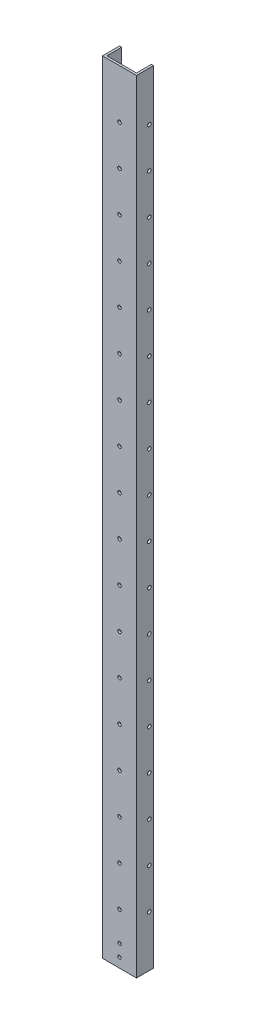
from build123d import *

# Parameters (mm, degrees)
BOSS_EXTRUDE1_DEPTH = 1168.4
CUT_EXTRUDE1_REACH  = 27.4
SKETCH2_R           = 2.667
CUT_EXTRUDE2_REACH  = 27.4
SKETCH3_R           = 2.5527
CUT_EXTRUDE3_REACH  = 52.8
SKETCH4_R           = 2.667


with BuildPart() as part:
    # Sketch1 → Boss-Extrude1 (new body)
    with BuildSketch(Plane(origin=(0, 0, 0), x_dir=(1, 0, 0), z_dir=(0, 1, 0))):
        Polygon((3.175, 3.175), (3.175, 25.4), (0, 25.4), (0, 0), (50.8, 0), (50.8, 25.4), (47.625, 25.4), (47.625, 3.175), align=None)
    extrude(amount=BOSS_EXTRUDE1_DEPTH)

    # Sketch2 → Cut-Extrude1 (cut, up to next)
    with BuildSketch(Plane.XY, mode=Mode.PRIVATE) as cut_extrude1_sk1:
        with Locations((25.4, 76.2)):
            Circle(SKETCH2_R)
    cut_extrude1_tool1 = extrude(cut_extrude1_sk1.sketch, amount=-CUT_EXTRUDE1_REACH, mode=Mode.PRIVATE) & part.part
    add(cut_extrude1_tool1.solids().sort_by_distance((25.4, 76.2, 0))[0], mode=Mode.SUBTRACT)
    # Sketch2 → Cut-Extrude1 (cut, up to next)
    with BuildSketch(Plane.XY, mode=Mode.PRIVATE) as cut_extrude1_sk2:
        with Locations((25.4, 136.144)):
            Circle(SKETCH2_R)
    cut_extrude1_tool2 = extrude(cut_extrude1_sk2.sketch, amount=-CUT_EXTRUDE1_REACH, mode=Mode.PRIVATE) & part.part
    add(cut_extrude1_tool2.solids().sort_by_distance((25.4, 136.144, 0))[0], mode=Mode.SUBTRACT)
    # Sketch2 → Cut-Extrude1 (cut, up to next)
    with BuildSketch(Plane.XY, mode=Mode.PRIVATE) as cut_extrude1_sk3:
        with Locations((25.4, 196.088)):
            Circle(SKETCH2_R)
    cut_extrude1_tool3 = extrude(cut_extrude1_sk3.sketch, amount=-CUT_EXTRUDE1_REACH, mode=Mode.PRIVATE) & part.part
    add(cut_extrude1_tool3.solids().sort_by_distance((25.4, 196.088, 0))[0], mode=Mode.SUBTRACT)
    # Sketch2 → Cut-Extrude1 (cut, up to next)
    with BuildSketch(Plane.XY, mode=Mode.PRIVATE) as cut_extrude1_sk4:
        with Locations((25.4, 256.032)):
            Circle(SKETCH2_R)
    cut_extrude1_tool4 = extrude(cut_extrude1_sk4.sketch, amount=-CUT_EXTRUDE1_REACH, mode=Mode.PRIVATE) & part.part
    add(cut_extrude1_tool4.solids().sort_by_distance((25.4, 256.032, 0))[0], mode=Mode.SUBTRACT)
    # Sketch2 → Cut-Extrude1 (cut, up to next)
    with BuildSketch(Plane.XY, mode=Mode.PRIVATE) as cut_extrude1_sk5:
        with Locations((25.4, 315.976)):
            Circle(SKETCH2_R)
    cut_extrude1_tool5 = extrude(cut_extrude1_sk5.sketch, amount=-CUT_EXTRUDE1_REACH, mode=Mode.PRIVATE) & part.part
    add(cut_extrude1_tool5.solids().sort_by_distance((25.4, 315.976, 0))[0], mode=Mode.SUBTRACT)
    # Sketch2 → Cut-Extrude1 (cut, up to next)
    with BuildSketch(Plane.XY, mode=Mode.PRIVATE) as cut_extrude1_sk6:
        with Locations((25.4, 375.92)):
            Circle(SKETCH2_R)
    cut_extrude1_tool6 = extrude(cut_extrude1_sk6.sketch, amount=-CUT_EXTRUDE1_REACH, mode=Mode.PRIVATE) & part.part
    add(cut_extrude1_tool6.solids().sort_by_distance((25.4, 375.92, 0))[0], mode=Mode.SUBTRACT)
    # Sketch2 → Cut-Extrude1 (cut, up to next)
    with BuildSketch(Plane.XY, mode=Mode.PRIVATE) as cut_extrude1_sk7:
        with Locations((25.4, 435.864)):
            Circle(SKETCH2_R)
    cut_extrude1_tool7 = extrude(cut_extrude1_sk7.sketch, amount=-CUT_EXTRUDE1_REACH, mode=Mode.PRIVATE) & part.part
    add(cut_extrude1_tool7.solids().sort_by_distance((25.4, 435.864, 0))[0], mode=Mode.SUBTRACT)
    # Sketch2 → Cut-Extrude1 (cut, up to next)
    with BuildSketch(Plane.XY, mode=Mode.PRIVATE) as cut_extrude1_sk8:
        with Locations((25.4, 495.808)):
            Circle(SKETCH2_R)
    cut_extrude1_tool8 = extrude(cut_extrude1_sk8.sketch, amount=-CUT_EXTRUDE1_REACH, mode=Mode.PRIVATE) & part.part
    add(cut_extrude1_tool8.solids().sort_by_distance((25.4, 495.808, 0))[0], mode=Mode.SUBTRACT)
    # Sketch2 → Cut-Extrude1 (cut, up to next)
    with BuildSketch(Plane.XY, mode=Mode.PRIVATE) as cut_extrude1_sk9:
        with Locations((25.4, 555.752)):
            Circle(SKETCH2_R)
    cut_extrude1_tool9 = extrude(cut_extrude1_sk9.sketch, amount=-CUT_EXTRUDE1_REACH, mode=Mode.PRIVATE) & part.part
    add(cut_extrude1_tool9.solids().sort_by_distance((25.4, 555.752, 0))[0], mode=Mode.SUBTRACT)
    # Sketch2 → Cut-Extrude1 (cut, up to next)
    with BuildSketch(Plane.XY, mode=Mode.PRIVATE) as cut_extrude1_sk10:
        with Locations((25.4, 615.696)):
            Circle(SKETCH2_R)
    cut_extrude1_tool10 = extrude(cut_extrude1_sk10.sketch, amount=-CUT_EXTRUDE1_REACH, mode=Mode.PRIVATE) & part.part
    add(cut_extrude1_tool10.solids().sort_by_distance((25.4, 615.696, 0))[0], mode=Mode.SUBTRACT)
    # Sketch2 → Cut-Extrude1 (cut, up to next)
    with BuildSketch(Plane.XY, mode=Mode.PRIVATE) as cut_extrude1_sk11:
        with Locations((25.4, 675.64)):
            Circle(SKETCH2_R)
    cut_extrude1_tool11 = extrude(cut_extrude1_sk11.sketch, amount=-CUT_EXTRUDE1_REACH, mode=Mode.PRIVATE) & part.part
    add(cut_extrude1_tool11.solids().sort_by_distance((25.4, 675.64, 0))[0], mode=Mode.SUBTRACT)
    # Sketch2 → Cut-Extrude1 (cut, up to next)
    with BuildSketch(Plane.XY, mode=Mode.PRIVATE) as cut_extrude1_sk12:
        with Locations((25.4, 735.584)):
            Circle(SKETCH2_R)
    cut_extrude1_tool12 = extrude(cut_extrude1_sk12.sketch, amount=-CUT_EXTRUDE1_REACH, mode=Mode.PRIVATE) & part.part
    add(cut_extrude1_tool12.solids().sort_by_distance((25.4, 735.584, 0))[0], mode=Mode.SUBTRACT)
    # Sketch2 → Cut-Extrude1 (cut, up to next)
    with BuildSketch(Plane.XY, mode=Mode.PRIVATE) as cut_extrude1_sk13:
        with Locations((25.4, 795.528)):
            Circle(SKETCH2_R)
    cut_extrude1_tool13 = extrude(cut_extrude1_sk13.sketch, amount=-CUT_EXTRUDE1_REACH, mode=Mode.PRIVATE) & part.part
    add(cut_extrude1_tool13.solids().sort_by_distance((25.4, 795.528, 0))[0], mode=Mode.SUBTRACT)
    # Sketch2 → Cut-Extrude1 (cut, up to next)
    with BuildSketch(Plane.XY, mode=Mode.PRIVATE) as cut_extrude1_sk14:
        with Locations((25.4, 855.472)):
            Circle(SKETCH2_R)
    cut_extrude1_tool14 = extrude(cut_extrude1_sk14.sketch, amount=-CUT_EXTRUDE1_REACH, mode=Mode.PRIVATE) & part.part
    add(cut_extrude1_tool14.solids().sort_by_distance((25.4, 855.472, 0))[0], mode=Mode.SUBTRACT)
    # Sketch2 → Cut-Extrude1 (cut, up to next)
    with BuildSketch(Plane.XY, mode=Mode.PRIVATE) as cut_extrude1_sk15:
        with Locations((25.4, 915.416)):
            Circle(SKETCH2_R)
    cut_extrude1_tool15 = extrude(cut_extrude1_sk15.sketch, amount=-CUT_EXTRUDE1_REACH, mode=Mode.PRIVATE) & part.part
    add(cut_extrude1_tool15.solids().sort_by_distance((25.4, 915.416, 0))[0], mode=Mode.SUBTRACT)
    # Sketch2 → Cut-Extrude1 (cut, up to next)
    with BuildSketch(Plane.XY, mode=Mode.PRIVATE) as cut_extrude1_sk16:
        with Locations((25.4, 975.36)):
            Circle(SKETCH2_R)
    cut_extrude1_tool16 = extrude(cut_extrude1_sk16.sketch, amount=-CUT_EXTRUDE1_REACH, mode=Mode.PRIVATE) & part.part
    add(cut_extrude1_tool16.solids().sort_by_distance((25.4, 975.36, 0))[0], mode=Mode.SUBTRACT)
    # Sketch2 → Cut-Extrude1 (cut, up to next)
    with BuildSketch(Plane.XY, mode=Mode.PRIVATE) as cut_extrude1_sk17:
        with Locations((25.4, 1035.304)):
            Circle(SKETCH2_R)
    cut_extrude1_tool17 = extrude(cut_extrude1_sk17.sketch, amount=-CUT_EXTRUDE1_REACH, mode=Mode.PRIVATE) & part.part
    add(cut_extrude1_tool17.solids().sort_by_distance((25.4, 1035.304, 0))[0], mode=Mode.SUBTRACT)
    # Sketch2 → Cut-Extrude1 (cut, up to next)
    with BuildSketch(Plane.XY, mode=Mode.PRIVATE) as cut_extrude1_sk18:
        with Locations((25.4, 1095.248)):
            Circle(SKETCH2_R)
    cut_extrude1_tool18 = extrude(cut_extrude1_sk18.sketch, amount=-CUT_EXTRUDE1_REACH, mode=Mode.PRIVATE) & part.part
    add(cut_extrude1_tool18.solids().sort_by_distance((25.4, 1095.248, 0))[0], mode=Mode.SUBTRACT)

    # Sketch3 → Cut-Extrude2 (cut, up to next)
    with BuildSketch(Plane.XY, mode=Mode.PRIVATE) as cut_extrude2_sk1:
        with Locations((25.4, 32.131)):
            Circle(SKETCH3_R)
    cut_extrude2_tool1 = extrude(cut_extrude2_sk1.sketch, amount=-CUT_EXTRUDE2_REACH, mode=Mode.PRIVATE) & part.part
    add(cut_extrude2_tool1.solids().sort_by_distance((25.4, 32.131, 0))[0], mode=Mode.SUBTRACT)
    # Sketch3 → Cut-Extrude2 (cut, up to next)
    with BuildSketch(Plane.XY, mode=Mode.PRIVATE) as cut_extrude2_sk2:
        with Locations((25.4, 14.2875)):
            Circle(SKETCH3_R)
    cut_extrude2_tool2 = extrude(cut_extrude2_sk2.sketch, amount=-CUT_EXTRUDE2_REACH, mode=Mode.PRIVATE) & part.part
    add(cut_extrude2_tool2.solids().sort_by_distance((25.4, 14.2875, 0))[0], mode=Mode.SUBTRACT)

    # Sketch4 → Cut-Extrude3 (cut, up to next)
    with BuildSketch(Plane.ZY.offset(-50.8), mode=Mode.PRIVATE) as cut_extrude3_sk1:
        with Locations((-19.05, 76.2)):
            Circle(SKETCH4_R)
    cut_extrude3_tool1 = extrude(cut_extrude3_sk1.sketch, amount=CUT_EXTRUDE3_REACH, mode=Mode.PRIVATE) & part.part
    add(cut_extrude3_tool1.solids().sort_by_distance((50.8, 76.2, -19.05))[0], mode=Mode.SUBTRACT)
    # Sketch4 → Cut-Extrude3 (cut, up to next)
    with BuildSketch(Plane.ZY.offset(-50.8), mode=Mode.PRIVATE) as cut_extrude3_sk2:
        with Locations((-19.05, 136.144)):
            Circle(SKETCH4_R)
    cut_extrude3_tool2 = extrude(cut_extrude3_sk2.sketch, amount=CUT_EXTRUDE3_REACH, mode=Mode.PRIVATE) & part.part
    add(cut_extrude3_tool2.solids().sort_by_distance((50.8, 136.144, -19.05))[0], mode=Mode.SUBTRACT)
    # Sketch4 → Cut-Extrude3 (cut, up to next)
    with BuildSketch(Plane.ZY.offset(-50.8), mode=Mode.PRIVATE) as cut_extrude3_sk3:
        with Locations((-19.05, 196.088)):
            Circle(SKETCH4_R)
    cut_extrude3_tool3 = extrude(cut_extrude3_sk3.sketch, amount=CUT_EXTRUDE3_REACH, mode=Mode.PRIVATE) & part.part
    add(cut_extrude3_tool3.solids().sort_by_distance((50.8, 196.088, -19.05))[0], mode=Mode.SUBTRACT)
    # Sketch4 → Cut-Extrude3 (cut, up to next)
    with BuildSketch(Plane.ZY.offset(-50.8), mode=Mode.PRIVATE) as cut_extrude3_sk4:
        with Locations((-19.05, 256.032)):
            Circle(SKETCH4_R)
    cut_extrude3_tool4 = extrude(cut_extrude3_sk4.sketch, amount=CUT_EXTRUDE3_REACH, mode=Mode.PRIVATE) & part.part
    add(cut_extrude3_tool4.solids().sort_by_distance((50.8, 256.032, -19.05))[0], mode=Mode.SUBTRACT)
    # Sketch4 → Cut-Extrude3 (cut, up to next)
    with BuildSketch(Plane.ZY.offset(-50.8), mode=Mode.PRIVATE) as cut_extrude3_sk5:
        with Locations((-19.05, 315.976)):
            Circle(SKETCH4_R)
    cut_extrude3_tool5 = extrude(cut_extrude3_sk5.sketch, amount=CUT_EXTRUDE3_REACH, mode=Mode.PRIVATE) & part.part
    add(cut_extrude3_tool5.solids().sort_by_distance((50.8, 315.976, -19.05))[0], mode=Mode.SUBTRACT)
    # Sketch4 → Cut-Extrude3 (cut, up to next)
    with BuildSketch(Plane.ZY.offset(-50.8), mode=Mode.PRIVATE) as cut_extrude3_sk6:
        with Locations((-19.05, 375.92)):
            Circle(SKETCH4_R)
    cut_extrude3_tool6 = extrude(cut_extrude3_sk6.sketch, amount=CUT_EXTRUDE3_REACH, mode=Mode.PRIVATE) & part.part
    add(cut_extrude3_tool6.solids().sort_by_distance((50.8, 375.92, -19.05))[0], mode=Mode.SUBTRACT)
    # Sketch4 → Cut-Extrude3 (cut, up to next)
    with BuildSketch(Plane.ZY.offset(-50.8), mode=Mode.PRIVATE) as cut_extrude3_sk7:
        with Locations((-19.05, 435.864)):
            Circle(SKETCH4_R)
    cut_extrude3_tool7 = extrude(cut_extrude3_sk7.sketch, amount=CUT_EXTRUDE3_REACH, mode=Mode.PRIVATE) & part.part
    add(cut_extrude3_tool7.solids().sort_by_distance((50.8, 435.864, -19.05))[0], mode=Mode.SUBTRACT)
    # Sketch4 → Cut-Extrude3 (cut, up to next)
    with BuildSketch(Plane.ZY.offset(-50.8), mode=Mode.PRIVATE) as cut_extrude3_sk8:
        with Locations((-19.05, 495.808)):
            Circle(SKETCH4_R)
    cut_extrude3_tool8 = extrude(cut_extrude3_sk8.sketch, amount=CUT_EXTRUDE3_REACH, mode=Mode.PRIVATE) & part.part
    add(cut_extrude3_tool8.solids().sort_by_distance((50.8, 495.808, -19.05))[0], mode=Mode.SUBTRACT)
    # Sketch4 → Cut-Extrude3 (cut, up to next)
    with BuildSketch(Plane.ZY.offset(-50.8), mode=Mode.PRIVATE) as cut_extrude3_sk9:
        with Locations((-19.05, 555.752)):
            Circle(SKETCH4_R)
    cut_extrude3_tool9 = extrude(cut_extrude3_sk9.sketch, amount=CUT_EXTRUDE3_REACH, mode=Mode.PRIVATE) & part.part
    add(cut_extrude3_tool9.solids().sort_by_distance((50.8, 555.752, -19.05))[0], mode=Mode.SUBTRACT)
    # Sketch4 → Cut-Extrude3 (cut, up to next)
    with BuildSketch(Plane.ZY.offset(-50.8), mode=Mode.PRIVATE) as cut_extrude3_sk10:
        with Locations((-19.05, 615.696)):
            Circle(SKETCH4_R)
    cut_extrude3_tool10 = extrude(cut_extrude3_sk10.sketch, amount=CUT_EXTRUDE3_REACH, mode=Mode.PRIVATE) & part.part
    add(cut_extrude3_tool10.solids().sort_by_distance((50.8, 615.696, -19.05))[0], mode=Mode.SUBTRACT)
    # Sketch4 → Cut-Extrude3 (cut, up to next)
    with BuildSketch(Plane.ZY.offset(-50.8), mode=Mode.PRIVATE) as cut_extrude3_sk11:
        with Locations((-19.05, 675.64)):
            Circle(SKETCH4_R)
    cut_extrude3_tool11 = extrude(cut_extrude3_sk11.sketch, amount=CUT_EXTRUDE3_REACH, mode=Mode.PRIVATE) & part.part
    add(cut_extrude3_tool11.solids().sort_by_distance((50.8, 675.64, -19.05))[0], mode=Mode.SUBTRACT)
    # Sketch4 → Cut-Extrude3 (cut, up to next)
    with BuildSketch(Plane.ZY.offset(-50.8), mode=Mode.PRIVATE) as cut_extrude3_sk12:
        with Locations((-19.05, 735.584)):
            Circle(SKETCH4_R)
    cut_extrude3_tool12 = extrude(cut_extrude3_sk12.sketch, amount=CUT_EXTRUDE3_REACH, mode=Mode.PRIVATE) & part.part
    add(cut_extrude3_tool12.solids().sort_by_distance((50.8, 735.584, -19.05))[0], mode=Mode.SUBTRACT)
    # Sketch4 → Cut-Extrude3 (cut, up to next)
    with BuildSketch(Plane.ZY.offset(-50.8), mode=Mode.PRIVATE) as cut_extrude3_sk13:
        with Locations((-19.05, 795.528)):
            Circle(SKETCH4_R)
    cut_extrude3_tool13 = extrude(cut_extrude3_sk13.sketch, amount=CUT_EXTRUDE3_REACH, mode=Mode.PRIVATE) & part.part
    add(cut_extrude3_tool13.solids().sort_by_distance((50.8, 795.528, -19.05))[0], mode=Mode.SUBTRACT)
    # Sketch4 → Cut-Extrude3 (cut, up to next)
    with BuildSketch(Plane.ZY.offset(-50.8), mode=Mode.PRIVATE) as cut_extrude3_sk14:
        with Locations((-19.05, 855.472)):
            Circle(SKETCH4_R)
    cut_extrude3_tool14 = extrude(cut_extrude3_sk14.sketch, amount=CUT_EXTRUDE3_REACH, mode=Mode.PRIVATE) & part.part
    add(cut_extrude3_tool14.solids().sort_by_distance((50.8, 855.472, -19.05))[0], mode=Mode.SUBTRACT)
    # Sketch4 → Cut-Extrude3 (cut, up to next)
    with BuildSketch(Plane.ZY.offset(-50.8), mode=Mode.PRIVATE) as cut_extrude3_sk15:
        with Locations((-19.05, 915.416)):
            Circle(SKETCH4_R)
    cut_extrude3_tool15 = extrude(cut_extrude3_sk15.sketch, amount=CUT_EXTRUDE3_REACH, mode=Mode.PRIVATE) & part.part
    add(cut_extrude3_tool15.solids().sort_by_distance((50.8, 915.416, -19.05))[0], mode=Mode.SUBTRACT)
    # Sketch4 → Cut-Extrude3 (cut, up to next)
    with BuildSketch(Plane.ZY.offset(-50.8), mode=Mode.PRIVATE) as cut_extrude3_sk16:
        with Locations((-19.05, 975.36)):
            Circle(SKETCH4_R)
    cut_extrude3_tool16 = extrude(cut_extrude3_sk16.sketch, amount=CUT_EXTRUDE3_REACH, mode=Mode.PRIVATE) & part.part
    add(cut_extrude3_tool16.solids().sort_by_distance((50.8, 975.36, -19.05))[0], mode=Mode.SUBTRACT)
    # Sketch4 → Cut-Extrude3 (cut, up to next)
    with BuildSketch(Plane.ZY.offset(-50.8), mode=Mode.PRIVATE) as cut_extrude3_sk17:
        with Locations((-19.05, 1035.304)):
            Circle(SKETCH4_R)
    cut_extrude3_tool17 = extrude(cut_extrude3_sk17.sketch, amount=CUT_EXTRUDE3_REACH, mode=Mode.PRIVATE) & part.part
    add(cut_extrude3_tool17.solids().sort_by_distance((50.8, 1035.304, -19.05))[0], mode=Mode.SUBTRACT)
    # Sketch4 → Cut-Extrude3 (cut, up to next)
    with BuildSketch(Plane.ZY.offset(-50.8), mode=Mode.PRIVATE) as cut_extrude3_sk18:
        with Locations((-19.05, 1095.248)):
            Circle(SKETCH4_R)
    cut_extrude3_tool18 = extrude(cut_extrude3_sk18.sketch, amount=CUT_EXTRUDE3_REACH, mode=Mode.PRIVATE) & part.part
    add(cut_extrude3_tool18.solids().sort_by_distance((50.8, 1095.248, -19.05))[0], mode=Mode.SUBTRACT)


solid = part.part
